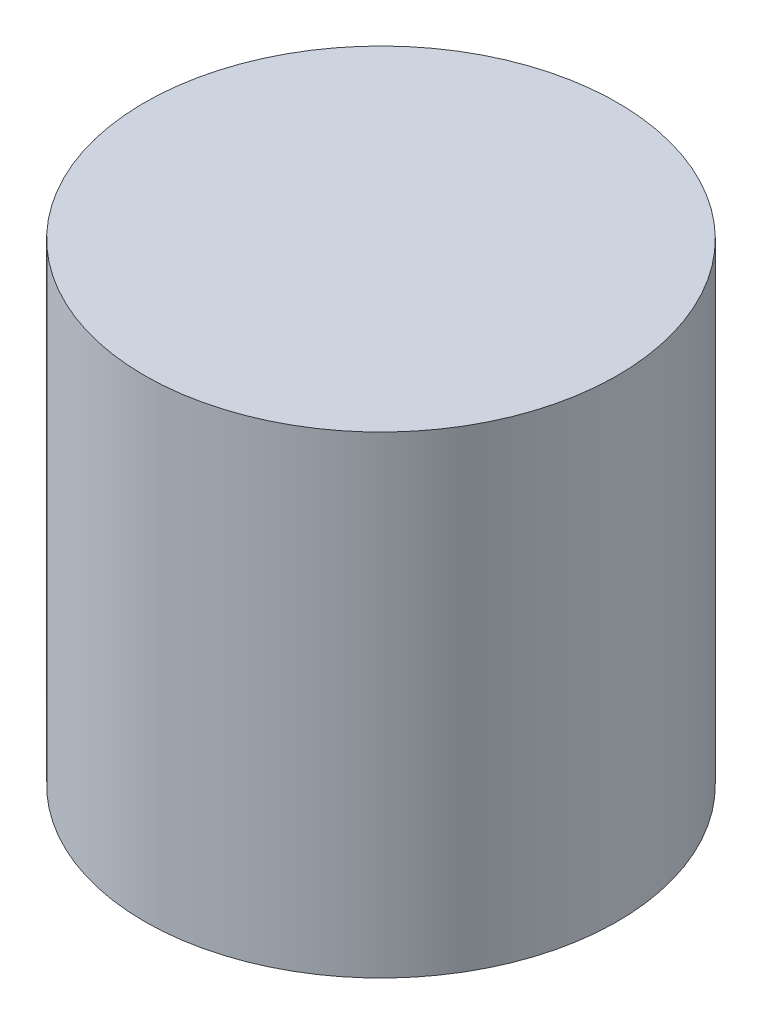
from build123d import *

# Parameters (mm, degrees)
SKETCH1_R           = 2.38125
BOSS_EXTRUDE1_DEPTH = 2.38125


with BuildPart() as part:
    # Sketch1 → Boss-Extrude1 (new body, symmetric)
    with BuildSketch(Plane(origin=(0, 0, 0), x_dir=(1, 0, 0), z_dir=(0, 1, 0))):
        Circle(SKETCH1_R)
    extrude(amount=BOSS_EXTRUDE1_DEPTH, both=True)


solid = part.part
